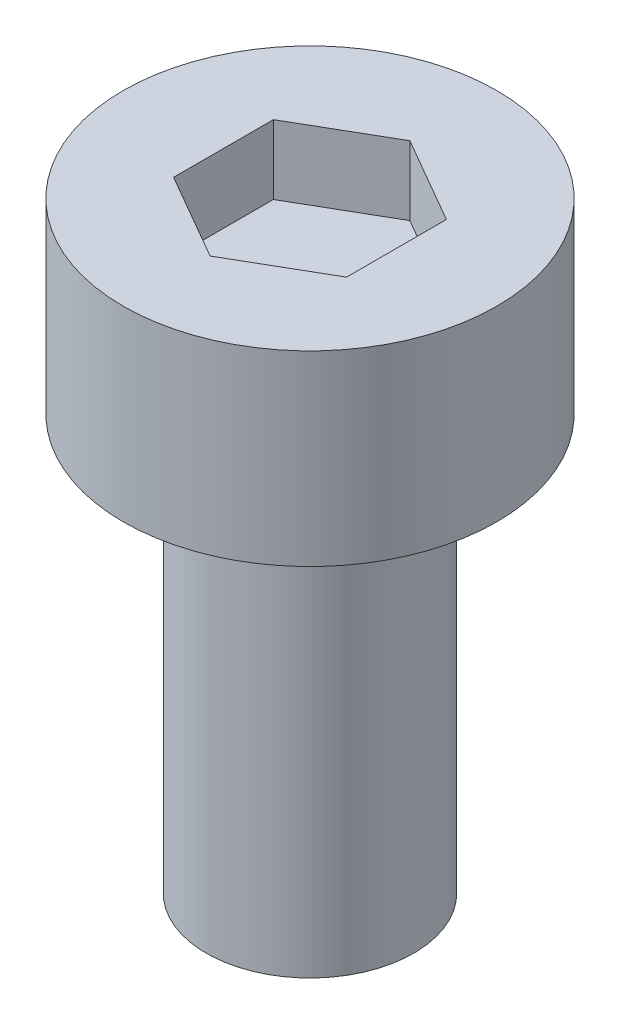
from build123d import *

# Parameters (mm, degrees)
SKETCH1_R           = 2.7
BOSS_EXTRUDE1_DEPTH = 2.7
CUT_EXTRUDE1_DEPTH  = 1
SKETCH3_R           = 1.5
BOSS_EXTRUDE2_DEPTH = 6


with BuildPart() as part:
    # Sketch1 → Boss-Extrude1 (new body)
    with BuildSketch(Plane(origin=(0, 0, 0), x_dir=(1, 0, 0), z_dir=(0, 1, 0))):
        Circle(SKETCH1_R)
    extrude(amount=BOSS_EXTRUDE1_DEPTH)

    # Sketch2 → Cut-Extrude1 (cut)
    with BuildSketch(Plane(origin=(0, 2.7, 0), x_dir=(1, 0, 0), z_dir=(0, 1, 0))):
        Polygon((0, 1.443375673), (-1.25, 0.721687836), (-1.25, -0.721687836), (0, -1.443375673), (1.25, -0.721687836), (1.25, 0.721687836), align=None)
    extrude(amount=-CUT_EXTRUDE1_DEPTH, mode=Mode.SUBTRACT)

    # Sketch3 → Boss-Extrude2 (add)
    with BuildSketch(Plane.XZ):
        Circle(SKETCH3_R)
    extrude(amount=BOSS_EXTRUDE2_DEPTH)


solid = part.part
